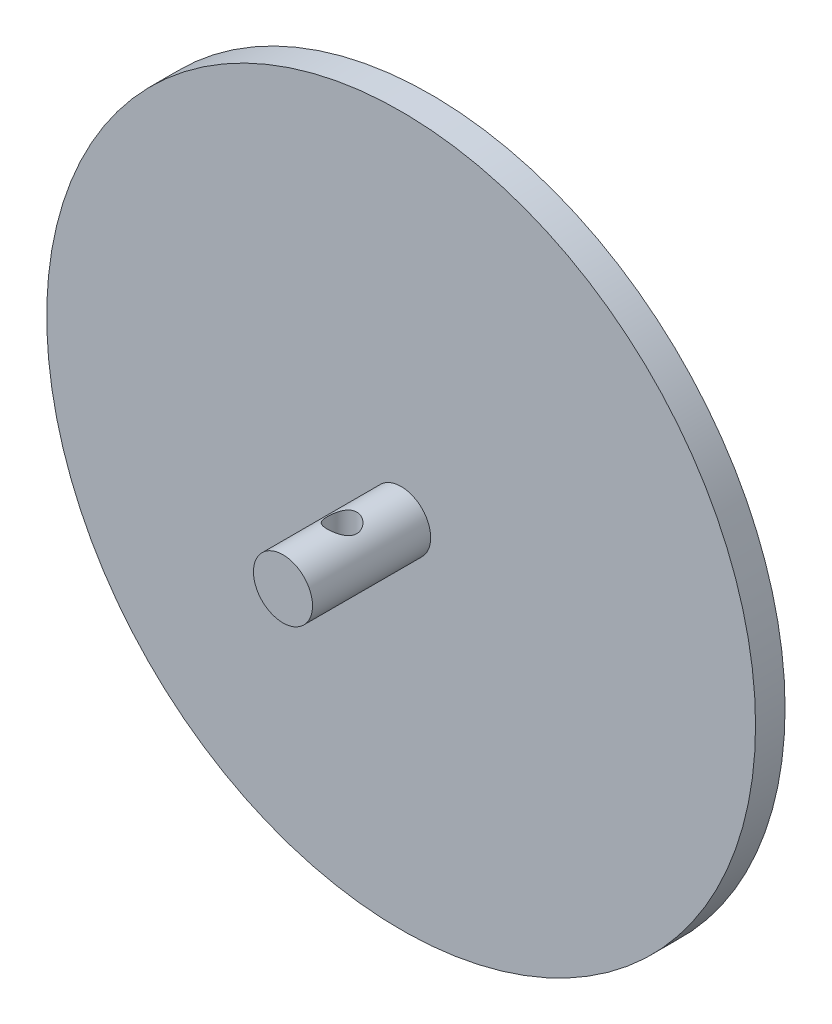
from build123d import *

# Parameters (mm, degrees)
SKETCH2_R               = 6.35
BOSS_EXTRUDE1_DEPTH     = 25.4
SKETCH3_R               = 3.175
CUT_EXTRUDE1_DEPTH      = 7.35
CUT_EXTRUDE1_DEPTH_BACK = 7.35


with BuildPart() as part:
    # Sketch2 → Boss-Extrude1 (new body)
    with BuildSketch(Plane.XY):
        Circle(SKETCH2_R)
    extrude(amount=BOSS_EXTRUDE1_DEPTH)

    # Sketch3 → Cut-Extrude1 (cut, two sides)
    with BuildSketch(Plane(origin=(0, 0, 0), x_dir=(1, 0, 0), z_dir=(0, 1, 0))) as cut_extrude1_sk:
        with Locations(Location((0, -12.7, 0), (0, 0, 270))):  # turned: the seam where the file's is
            Circle(SKETCH3_R)
    extrude(amount=CUT_EXTRUDE1_DEPTH, mode=Mode.SUBTRACT)
    extrude(cut_extrude1_sk.sketch, amount=-CUT_EXTRUDE1_DEPTH_BACK, mode=Mode.SUBTRACT)

    # Sketch7 → Revolve2 (revolve)
    with BuildSketch(Plane(origin=(0, 0, 0), x_dir=(1, 0, 0), z_dir=(0, 1, 0))):
        with BuildLine():
            Line((-69.85, 6.35), (-76.2, 6.35))
            Line((-76.2, 6.35), (-76.2, 0))
            Line((-76.2, 0), (0, 0))
            Line((0, 0), (0, 3.175))
            ThreePointArc((0, 3.175), (-34.961060929, 3.969159572), (-69.85, 6.35))
        make_face()
    revolve(axis=Axis((0, 0, 50), (0, 0, -1)))


solid = part.part
